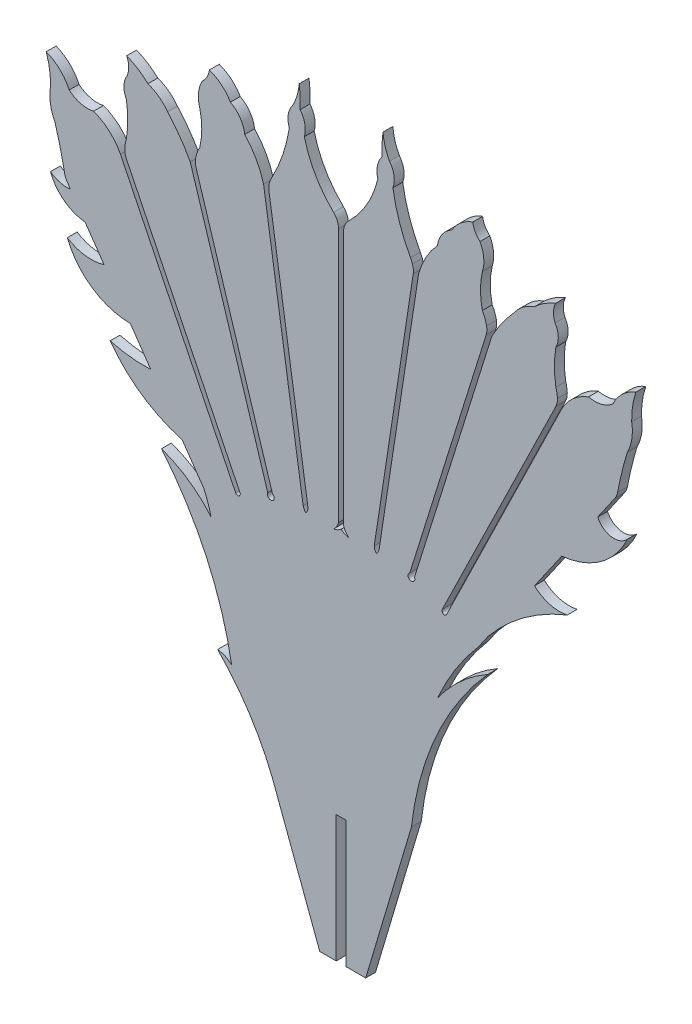
from build123d import *

# Parameters (mm, degrees)
BOSS_EXTRUDE1_DEPTH = 1.524


with BuildPart() as part:
    # Sketch1 → Boss-Extrude1 (new body)
    with BuildSketch(Plane.XY):
        with BuildLine():
            Line((11.363984553, 5.948125728), (23.281158182, 44.06181755))
            ThreePointArc((23.281158182, 44.06181755), (23.370600933, 44.30393106), (23.484152898, 44.535717403))
            ThreePointArc((23.484152898, 44.535717403), (25.043410315, 47.002352038), (26.874735369, 49.274315653))
            ThreePointArc((26.874735369, 49.274315653), (28.226460805, 50.633684707), (29.924320696, 51.523806985))
            ThreePointArc((29.924320696, 51.523806985), (31.469937452, 52.737372248), (33.217629747, 53.635839523))
            ThreePointArc((33.217629747, 53.635839523), (32.895922323, 52.301495643), (33.158467832, 50.954261769))
            ThreePointArc((33.158467832, 50.954261769), (33.640903096, 49.386087396), (33.270712076, 47.787690307))
            ThreePointArc((33.270712076, 47.787690307), (33.033119786, 45.104084507), (33.270712076, 42.420478707))
            ThreePointArc((33.270712076, 42.420478707), (33.434364381, 41.723839977), (33.509359109, 41.012177567))
            ThreePointArc((33.509359109, 41.012177567), (33.457784005, 40.385077254), (33.253640195, 39.789896527))
            Line((33.253640195, 39.789896527), (15.653873717, 3.779585164))
            ThreePointArc((15.653873717, 3.779585164), (15.828904994, 3.269969818), (16.338507225, 3.445039278))
            Line((16.338507225, 3.445039278), (34.175377396, 39.949862264))
            ThreePointArc((34.175377396, 39.949862264), (35.912148877, 42.178588174), (38.329347, 43.641717558))
            ThreePointArc((38.329347, 43.641717558), (40.336853485, 43.659063904), (42.113655551, 44.593599939))
            ThreePointArc((42.113655551, 44.593599939), (43.56558898, 46.619432414), (45.671272721, 47.952925526))
            ThreePointArc((45.671272721, 47.952925526), (45.146589776, 45.827396721), (45.011831062, 43.642218242))
            ThreePointArc((45.011831062, 43.642218242), (45.038223486, 41.366939176), (44.332639665, 39.203667843))
            ThreePointArc((44.332639665, 39.203667843), (43.496005333, 36.153020864), (42.825068079, 33.061702829))
            ThreePointArc((42.825068079, 33.061702829), (42.672258101, 32.552572382), (42.416829206, 32.086395612))
            Line((42.416829206, 32.086395612), (39.747277492, 28.234770387))
            ThreePointArc((39.747277492, 28.234770387), (41.850620302, 26.637078874), (44.332639665, 27.540543885))
            ThreePointArc((44.332639665, 27.540543885), (40.241943786, 22.501877384), (34.175377396, 20.19564125))
            Line((34.175377396, 20.19564125), (29.954869637, 14.106298959))
            ThreePointArc((29.954869637, 14.106298959), (32.331459674, 12.790469062), (35.047396255, 12.733223913))
            ThreePointArc((35.047396255, 12.733223913), (28.3215159, 9.005043284), (22.747372994, 3.707333569))
            Line((22.747372994, 3.707333569), (21.276881031, 1.585709961))
            ThreePointArc((21.276881031, 1.585709961), (17.725684349, -3.199883806), (14.924639146, -8.459831653))
            ThreePointArc((14.924639146, -8.459831653), (18.452425368, -4.489515005), (22.747372994, -1.365076687))
            ThreePointArc((22.747372994, -1.365076687), (14.745927086, -13.642829697), (10.893977206, -27.78244913))
            Line((10.893977206, -27.78244913), (3.806222882, -51.583591898))
            Line((3.806222882, -51.583591898), (0.760143336, -51.583820124))
            Line((0.760143336, -51.583820124), (0.758670945, -31.932223193))
            Line((0.758670945, -31.932223193), (-0.765329051, -31.932337379))
            Line((-0.765329051, -31.932337379), (-0.763856659, -51.58393431))
            Line((-0.763856659, -51.58393431), (-3.307128243, -51.584124864))
            Line((-3.307128243, -51.584124864), (-10.666253275, -31.933079203))
            ThreePointArc((-10.666253275, -31.933079203), (-14.253064161, -25.032845054), (-19.133489914, -18.978104092))
            ThreePointArc((-19.133489914, -18.978104092), (-17.946593447, -19.291980349), (-16.94939619, -20.008108243))
            ThreePointArc((-16.94939619, -20.008108243), (-20.8390962, -7.486634561), (-27.821224453, 3.611426278))
            ThreePointArc((-27.821224453, 3.611426278), (-23.624726674, 1.468477254), (-20.145148626, -1.708842486))
            ThreePointArc((-20.145148626, -1.708842486), (-20.616598399, -0.030218678), (-21.279253701, 1.582521452))
            Line((-21.279253701, 1.582521452), (-24.639467898, 6.429315478))
            ThreePointArc((-24.639467898, 6.429315478), (-30.865316248, 9.31746327), (-35.781578862, 14.106298959))
            ThreePointArc((-35.781578862, 14.106298959), (-32.659726787, 13.506645314), (-29.482142892, 13.41442025))
            Line((-29.482142892, 13.41442025), (-32.659726787, 17.997787183))
            ThreePointArc((-32.659726787, 17.997787183), (-38.550285955, 19.824696889), (-42.422783254, 24.624702207))
            ThreePointArc((-42.422783254, 24.624702207), (-39.652474162, 23.614248544), (-36.712574779, 23.843640537))
            Line((-36.712574779, 23.843640537), (-39.652474162, 28.084169839))
            ThreePointArc((-39.652474162, 28.084169839), (-42.926511244, 29.365334295), (-45.019485042, 32.190252321))
            ThreePointArc((-45.019485042, 32.190252321), (-43.551665232, 31.476745649), (-41.923774296, 31.360307392))
            Line((-41.923774296, 31.360307392), (-42.422783254, 32.080081041))
            ThreePointArc((-42.422783254, 32.080081041), (-42.678260474, 32.546198978), (-42.831135683, 33.055280221))
            ThreePointArc((-42.831135683, 33.055280221), (-43.50253649, 36.146500129), (-44.339628538, 39.197024095))
            ThreePointArc((-44.339628538, 39.197024095), (-45.045536516, 41.360189672), (-45.019485042, 43.635472667))
            ThreePointArc((-45.019485042, 43.635472667), (-45.154571202, 45.820630928), (-45.679572651, 47.946081086))
            ThreePointArc((-45.679572651, 47.946081086), (-43.57368911, 46.612903524), (-42.121452127, 44.587288643))
            ThreePointArc((-42.121452127, 44.587288643), (-40.344510041, 43.653018872), (-38.33700098, 43.63597335))
            ThreePointArc((-38.33700098, 43.63597335), (-35.92633891, 42.175728514), (-34.192591165, 39.953629201))
            Line((-34.192591165, 39.953629201), (-16.339108318, 3.440849895))
            ThreePointArc((-16.339108318, 3.440849895), (-15.829461207, 3.265942222), (-15.654572627, 3.775595886))
            Line((-15.654572627, 3.775595886), (-33.255888635, 39.765826407))
            ThreePointArc((-33.255888635, 39.765826407), (-33.458294281, 40.352013763), (-33.512618317, 40.969777926))
            ThreePointArc((-33.512618317, 40.969777926), (-33.439500426, 41.70291612), (-33.272342501, 42.420478706))
            ThreePointArc((-33.272342501, 42.420478706), (-33.034750211, 45.104084507), (-33.272342501, 47.787690307))
            ThreePointArc((-33.272342501, 47.787690307), (-33.64253352, 49.386087396), (-33.160098257, 50.954261768))
            ThreePointArc((-33.160098257, 50.954261768), (-32.897552748, 52.301495643), (-33.219260172, 53.635839523))
            ThreePointArc((-33.219260172, 53.635839523), (-31.471567877, 52.737372247), (-29.92595112, 51.523806984))
            ThreePointArc((-29.92595112, 51.523806984), (-28.22809123, 50.633684707), (-26.876365794, 49.274315653))
            ThreePointArc((-26.876365794, 49.274315653), (-24.975141943, 46.904172816), (-23.369878552, 44.324374636))
            Line((-23.369878552, 44.324374636), (-11.365201738, 5.945299261))
            ThreePointArc((-11.365201738, 5.945299261), (-10.735432481, 5.208308195), (-10.638016566, 6.172815991))
            Line((-10.638016566, 6.172815991), (-22.475681089, 43.998375111))
            ThreePointArc((-22.475681089, 43.998375111), (-22.587302738, 44.60904206), (-22.547460149, 45.228546767))
            ThreePointArc((-22.547460149, 45.228546767), (-22.293578912, 46.144812209), (-21.890805948, 47.006074064))
            ThreePointArc((-21.890805948, 47.006074064), (-21.585833387, 49.618231268), (-21.890805948, 52.230388472))
            ThreePointArc((-21.890805948, 52.230388472), (-22.0931539, 54.191633443), (-21.517243385, 56.077304042))
            ThreePointArc((-21.517243385, 56.077304042), (-20.766964347, 57.005013396), (-20.400706997, 58.140539193))
            ThreePointArc((-20.400706997, 58.140539193), (-18.533585036, 57.074607678), (-17.144783178, 55.433393552))
            ThreePointArc((-17.144783178, 55.433393552), (-15.645848352, 54.10159521), (-14.925377825, 52.230388472))
            ThreePointArc((-14.925377825, 52.230388472), (-13.154320405, 49.79343191), (-12.011500249, 47.006074064))
            Line((-12.011500249, 47.006074064), (-5.88566394, 6.938978444))
            ThreePointArc((-5.88566394, 6.938978444), (-5.731531507, 6.537613867), (-5.50399505, 6.172815991))
            ThreePointArc((-5.50399505, 6.172815991), (-5.230564163, 6.57662799), (-5.132445848, 7.054332267))
            Line((-5.132445848, 7.054332267), (-11.18229351, 46.557615217))
            ThreePointArc((-11.18229351, 46.557615217), (-11.200293975, 47.181162531), (-11.065771495, 47.790292215))
            ThreePointArc((-11.065771495, 47.790292215), (-10.885886385, 48.237100221), (-10.668903677, 48.667117141))
            ThreePointArc((-10.668903677, 48.667117141), (-9.016721425, 52.489673999), (-8.025517638, 56.534320112))
            ThreePointArc((-8.025517638, 56.534320112), (-8.195999112, 58.252457165), (-7.504732966, 59.834610754))
            ThreePointArc((-7.504732966, 59.834610754), (-6.819304123, 61.485119518), (-6.494788347, 63.242583995))
            ThreePointArc((-6.494788347, 63.242583995), (-6.347650461, 61.541759558), (-6.337838027, 59.834610754))
            ThreePointArc((-6.337838027, 59.834610754), (-5.620542259, 58.261563066), (-5.695535768, 56.534320112))
            ThreePointArc((-5.695535768, 56.534320112), (-3.993734919, 52.266140613), (-1.165816301, 48.644489242))
            ThreePointArc((-1.165816301, 48.644489242), (-0.589741954, 47.808862907), (-0.386833148, 46.814397703))
            Line((-0.386833148, 46.814397703), (-0.381815209, 7.432873767))
            ThreePointArc((-0.381815209, 7.432873767), (-0.685141379, 6.747672165), (-1.165816301, 6.172815991))
            ThreePointArc((-1.165816301, 6.172815991), (-0.547037627, 6.369123871), (-0.000724346, 6.719788427))
            ThreePointArc((-0.000724346, 6.719788427), (0.54567828, 6.369263103), (1.164506961, 6.173112917))
            ThreePointArc((1.164506961, 6.173112917), (0.68368556, 6.747846579), (0.380184785, 7.43297086))
            Line((0.380184785, 7.43297086), (0.375167094, 46.812546474))
            ThreePointArc((0.375167094, 46.812546474), (0.578415566, 47.808456574), (1.155866949, 48.644935365))
            ThreePointArc((1.155866949, 48.644935365), (3.988155451, 52.265630645), (5.693905343, 56.534320112))
            ThreePointArc((5.693905343, 56.534320112), (5.618911834, 58.261563066), (6.336207602, 59.834610754))
            ThreePointArc((6.336207602, 59.834610754), (6.346020036, 61.541759558), (6.493157922, 63.242583995))
            ThreePointArc((6.493157922, 63.242583995), (6.817673698, 61.485119518), (7.503102541, 59.834610754))
            ThreePointArc((7.503102541, 59.834610754), (8.194368687, 58.252457165), (8.023887213, 56.534320112))
            ThreePointArc((8.023887213, 56.534320112), (9.041511493, 52.411471843), (10.745711558, 48.521852433))
            ThreePointArc((10.745711558, 48.521852433), (10.909928473, 48.179534774), (11.05098113, 47.827039777))
            ThreePointArc((11.05098113, 47.827039777), (11.190505436, 47.210510051), (11.17346813, 46.578619502))
            Line((11.17346813, 46.578619502), (5.130911735, 7.05564001))
            ThreePointArc((5.130911735, 7.05564001), (5.229151784, 6.577960752), (5.502685569, 6.174218446))
            ThreePointArc((5.502685569, 6.174218446), (5.730129054, 6.539074296), (5.8841592, 6.940478138))
            Line((5.8841592, 6.940478138), (12.009610899, 47.005656857))
            ThreePointArc((12.009610899, 47.005656857), (13.15268998, 49.79343191), (14.9237474, 52.230388472))
            ThreePointArc((14.9237474, 52.230388472), (15.644217927, 54.10159521), (17.143152753, 55.433393552))
            ThreePointArc((17.143152753, 55.433393552), (18.531954611, 57.074607678), (20.399076571, 58.140539193))
            ThreePointArc((20.399076571, 58.140539193), (20.765333922, 57.005013396), (21.51561296, 56.077304043))
            ThreePointArc((21.51561296, 56.077304043), (22.091523475, 54.191633443), (21.889175523, 52.230388472))
            ThreePointArc((21.889175523, 52.230388472), (21.584202962, 49.618231268), (21.889175523, 47.006074064))
            ThreePointArc((21.889175523, 47.006074064), (22.284912345, 46.163755213), (22.53818583, 45.268232337))
            ThreePointArc((22.53818583, 45.268232337), (22.581964128, 44.64034958), (22.470009045, 44.020979452))
            Line((22.470009045, 44.020979452), (10.636706918, 6.175526786))
            ThreePointArc((10.636706918, 6.175526786), (10.734331529, 5.211055444), (11.363984553, 5.948125728))
        make_face()
    extrude(amount=BOSS_EXTRUDE1_DEPTH)


solid = part.part
